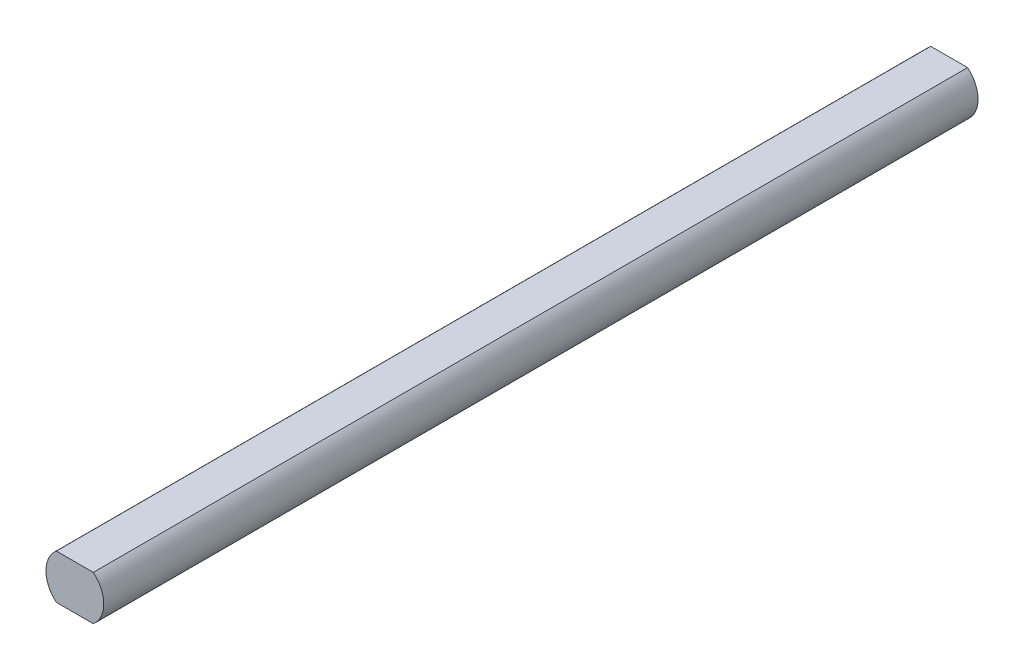
from build123d import *

# Parameters (mm, degrees)
RESSALTO_EXTRUS_O1_DEPTH = 118


with BuildPart() as part:
    # Esboço1 → Ressalto-extrusão1 (new body)
    with BuildSketch(Plane.XY):
        with BuildLine():
            Line((-2.491987159, 3), (2.491987159, 3))
            ThreePointArc((2.491987159, 3), (3.9, 0), (2.491987159, -3))
            Line((2.491987159, -3), (-2.491987159, -3))
            ThreePointArc((-2.491987159, -3), (-3.9, 0), (-2.491987159, 3))
        make_face()
    extrude(amount=RESSALTO_EXTRUS_O1_DEPTH)


solid = part.part
